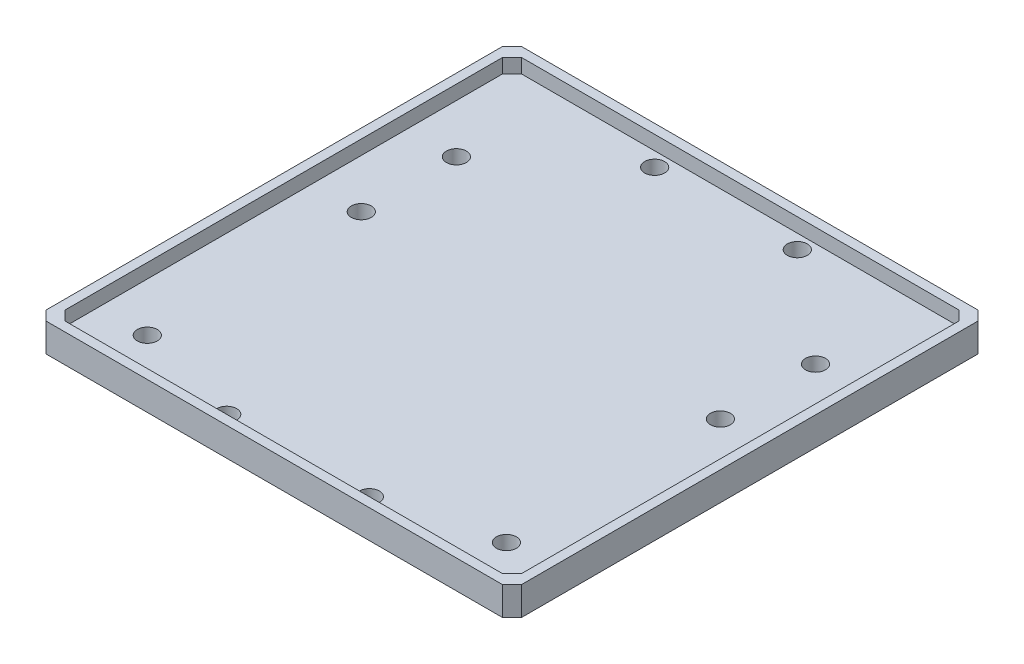
from build123d import *

# Parameters (mm, degrees)
SKETCH6_W           = 100
SKETCH6_H           = 100
SKETCH6_R           = 2.1
BOSS_EXTRUDE2_DEPTH = 3
BOSS_EXTRUDE3_DEPTH = 3
SKETCH8_W           = 96
SKETCH8_H           = 2
BOSS_EXTRUDE4_DEPTH = 3
CHAMFER1_SIZE       = 2
BOSS_EXTRUDE5_DEPTH = 3


with BuildPart() as part:
    # Sketch6 → Boss-Extrude2 (new body)
    with BuildSketch(Plane(origin=(0, 0, 0), x_dir=(1, 0, 0), z_dir=(0, 1, 0))):
        with Locations((39.444153985, -113.424821635)):
            Rectangle(SKETCH6_W, SKETCH6_H)
        with Locations((1.68480047, -87.360414745)):
            Circle(SKETCH6_R, mode=Mode.SUBTRACT)
        with Locations((1.68480047, -107.360414745)):
            Circle(SKETCH6_R, mode=Mode.SUBTRACT)
        with Locations((1.68480047, -152.360414745)):
            Circle(SKETCH6_R, mode=Mode.SUBTRACT)
        with Locations((24.444153985, -158.424821635)):
            Circle(SKETCH6_R, mode=Mode.SUBTRACT)
        with Locations((24.444153985, -68.424821635)):
            Circle(SKETCH6_R, mode=Mode.SUBTRACT)
        with Locations((54.444153985, -158.424821635)):
            Circle(SKETCH6_R, mode=Mode.SUBTRACT)
        with Locations((77.2035075, -152.360414745)):
            Circle(SKETCH6_R, mode=Mode.SUBTRACT)
        with Locations((77.2035075, -107.360414745)):
            Circle(SKETCH6_R, mode=Mode.SUBTRACT)
        with Locations((77.2035075, -87.360414745)):
            Circle(SKETCH6_R, mode=Mode.SUBTRACT)
        with Locations((54.444153985, -68.424821635)):
            Circle(SKETCH6_R, mode=Mode.SUBTRACT)
    extrude(amount=BOSS_EXTRUDE2_DEPTH)

    # Sketch7 → Boss-Extrude3 (add)
    with BuildSketch(Plane(origin=(0, 3, 0), x_dir=(1, 0, 0), z_dir=(0, 1, 0))):
        Polygon((-10.555846015, -63.424821635), (-10.555846015, -163.424821635), (-8.555846015, -163.424821635), (-8.555846015, -65.424821635), (87.444153985, -65.424821635), (87.444153985, -163.424821635), (89.444153985, -163.424821635), (89.444153985, -63.424821635), align=None)
    extrude(amount=BOSS_EXTRUDE3_DEPTH)

    # Sketch8 → Boss-Extrude4 (add)
    with BuildSketch(Plane(origin=(0, 3, 0), x_dir=(1, 0, 0), z_dir=(0, 1, 0))):
        with Locations((39.444153985, -162.424821635)):
            Rectangle(SKETCH8_W, SKETCH8_H)
    extrude(amount=BOSS_EXTRUDE4_DEPTH)

    # Chamfer1
    chamfer1_edges = [part.edges().sort_by_distance(p)[0] for p in [
        (-10.555846015, 3, 63.424821635),
        (89.444153985, 3, 63.424821635),
        (89.444153985, 3, 163.424821635),
        (-10.555846015, 3, 163.424821635),
    ]]
    chamfer(chamfer1_edges, length=CHAMFER1_SIZE)

    # Sketch9 → Boss-Extrude5 (add)
    with BuildSketch(Plane(origin=(0, 3, 0), x_dir=(1, 0, 0), z_dir=(0, 1, 0))):
        Polygon((-6.555846015, -65.424821635), (-8.555846015, -67.424821635), (-8.555846015, -65.424821635), align=None)
        Polygon((87.444153985, -67.424821635), (87.444153985, -65.424821635), (85.444153985, -65.424821635), align=None)
        Polygon((85.444153985, -161.424821635), (87.444153985, -159.424821635), (87.444153985, -161.424821635), align=None)
        Polygon((-8.555846015, -159.424821635), (-8.555846015, -161.424821635), (-6.555846015, -161.424821635), align=None)
    extrude(amount=BOSS_EXTRUDE5_DEPTH)


solid = part.part
